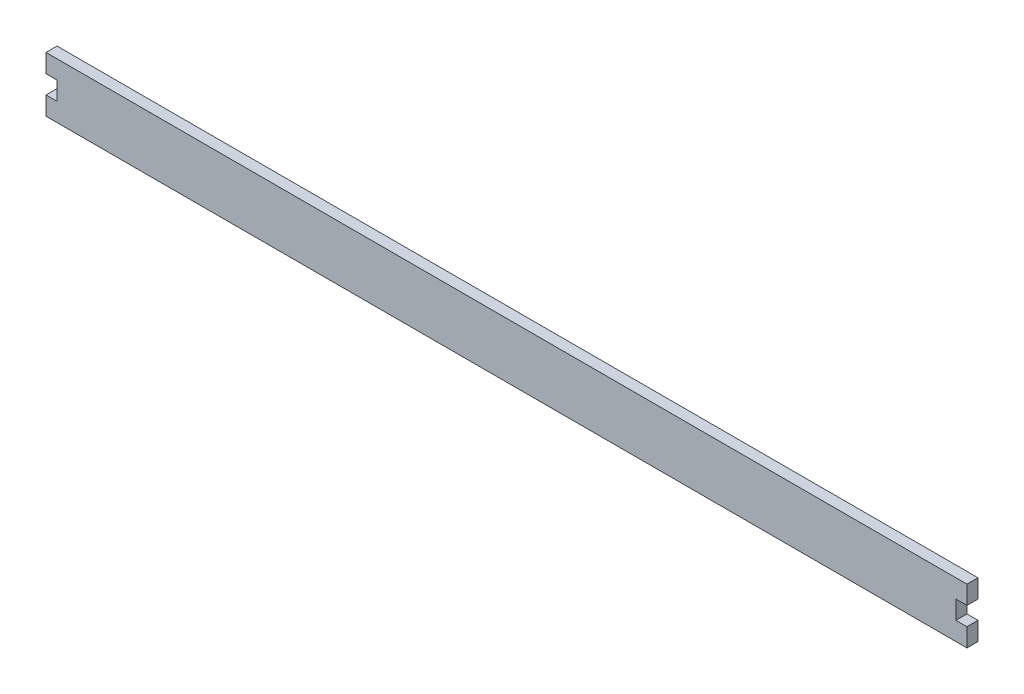
from build123d import *

# Parameters (mm, degrees)
SALIENTE_EXTRUIR1_DEPTH = 6


with BuildPart() as part:
    # Croquis1 → Saliente-Extruir1 (new body)
    with BuildSketch(Plane.XY):
        Polygon((428.795272116, 23.551135442), (-71.204727884, 23.551135442), (-71.204727884, 13.551135442), (-65.204727884, 13.551135442), (-65.204727884, 3.551135442), (-71.204727884, 3.551135442), (-71.204727884, -6.448864558), (428.795272116, -6.448864558), (428.795272116, 3.551135442), (422.795272116, 3.551135442), (422.795272116, 13.551135442), (428.795272116, 13.551135442), align=None)
    extrude(amount=SALIENTE_EXTRUIR1_DEPTH)


solid = part.part
